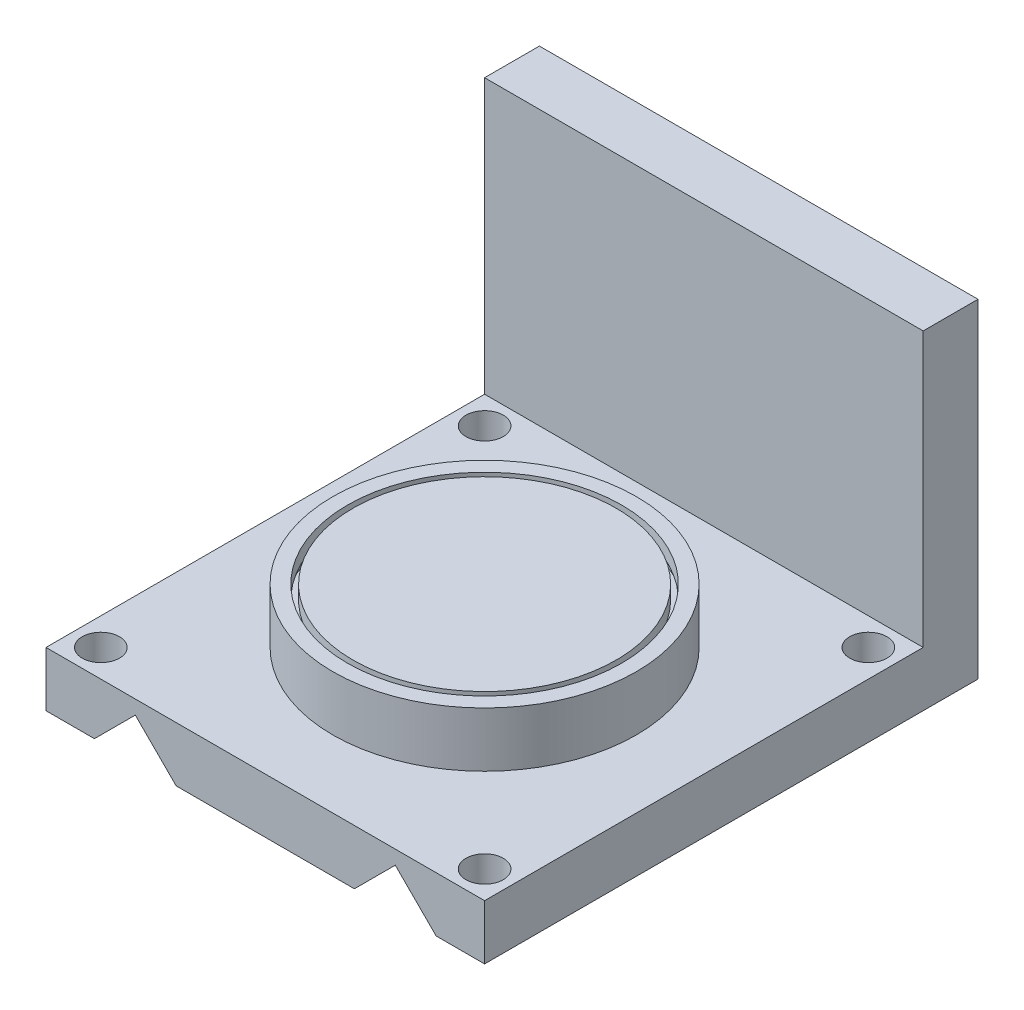
from build123d import *

# Parameters (mm, degrees)
SKETCH_5_W               = 40
SKETCH_5_H               = 40
EXTRUDE_2_DEPTH          = 5
CUT_EXTRUDE_2_DEPTH      = 21
CUT_EXTRUDE_2_DEPTH_BACK = 21
SKETCH_7_R               = 1.7
CUT_EXTRUDE_4_DEPTH      = 6
CUT_EXTRUDE_4_DEPTH_BACK = 1
SKETCH_8_R               = 13.836233659
EXTRUDE_3_DEPTH          = 5
SKETCH_9_R               = 12.5
SKETCH_9_R_2             = 12
CUT_EXTRUDE_5_DEPTH      = 2.5
SKETCH_11_R              = 13
SKETCH_11_R_2            = 11.5
CUT_EXTRUDE_6_DEPTH      = 1.25
SKETCH_13_W              = 40
SKETCH_13_H              = 5
EXTRUDE_5_DEPTH          = 30


with BuildPart() as part:
    # Эскиз5 → Бобышка-Вытянуть2 (new body)
    with BuildSketch(Plane(origin=(0, 0, 0), x_dir=(1, 0, 0), z_dir=(0, 1, 0))):
        Rectangle(SKETCH_5_W, SKETCH_5_H)
    extrude(amount=EXTRUDE_2_DEPTH)

    # Эскиз6 → Вырез-Вытянуть2 (cut, two sides)
    with BuildSketch(Plane.XY) as cut_extrude_2_sk:
        Polygon((8.127281001, 0), (11.855143598, 3.727862597), (15.583006195, 0), align=None)
        Polygon((-8.127281001, 0), (-11.855143598, 3.727862597), (-15.583006195, 0), align=None)
    extrude(amount=CUT_EXTRUDE_2_DEPTH, mode=Mode.SUBTRACT)
    extrude(cut_extrude_2_sk.sketch, amount=-CUT_EXTRUDE_2_DEPTH_BACK, mode=Mode.SUBTRACT)

    # Эскиз7 → Вырез-Вытянуть4 (cut, two sides)
    with BuildSketch(Plane(origin=(0, 0, 0), x_dir=(1, 0, 0), z_dir=(0, 1, 0))) as cut_extrude_4_sk:
        with Locations((-17.5, -17.5)):
            Circle(SKETCH_7_R)
        with Locations((-17.5, 17.5)):
            Circle(SKETCH_7_R)
        with Locations((17.5, 17.5)):
            Circle(SKETCH_7_R)
        with Locations((17.5, -17.5)):
            Circle(SKETCH_7_R)
    extrude(amount=CUT_EXTRUDE_4_DEPTH, mode=Mode.SUBTRACT)
    extrude(cut_extrude_4_sk.sketch, amount=-CUT_EXTRUDE_4_DEPTH_BACK, mode=Mode.SUBTRACT)

    # Эскиз8 → Бобышка-Вытянуть3 (add)
    with BuildSketch(Plane(origin=(0, 5, 0), x_dir=(1, 0, 0), z_dir=(0, 1, 0))):
        Circle(SKETCH_8_R)
    extrude(amount=EXTRUDE_3_DEPTH)

    # Эскиз9 → Вырез-Вытянуть5 (cut)
    with BuildSketch(Plane(origin=(0, 10, 0), x_dir=(1, 0, 0), z_dir=(0, 1, 0))):
        Circle(SKETCH_9_R)
        Circle(SKETCH_9_R_2, mode=Mode.SUBTRACT)
    extrude(amount=-CUT_EXTRUDE_5_DEPTH, mode=Mode.SUBTRACT)

    # Эскиз11 → Вырез-Вытянуть6 (cut)
    with BuildSketch(Plane(origin=(0, 7.5, 0), x_dir=(1, 0, 0), z_dir=(0, 1, 0))):
        Circle(SKETCH_11_R)
        Circle(SKETCH_11_R_2, mode=Mode.SUBTRACT)
    extrude(amount=CUT_EXTRUDE_6_DEPTH, mode=Mode.SUBTRACT)

    # Эскиз13 → Бобышка-Вытянуть5 (add)
    with BuildSketch(Plane(origin=(0, 0, 0), x_dir=(1, 0, 0), z_dir=(0, 1, 0))):
        with Locations((0, 22.5)):
            Rectangle(SKETCH_13_W, SKETCH_13_H)
    extrude(amount=EXTRUDE_5_DEPTH)


solid = part.part
